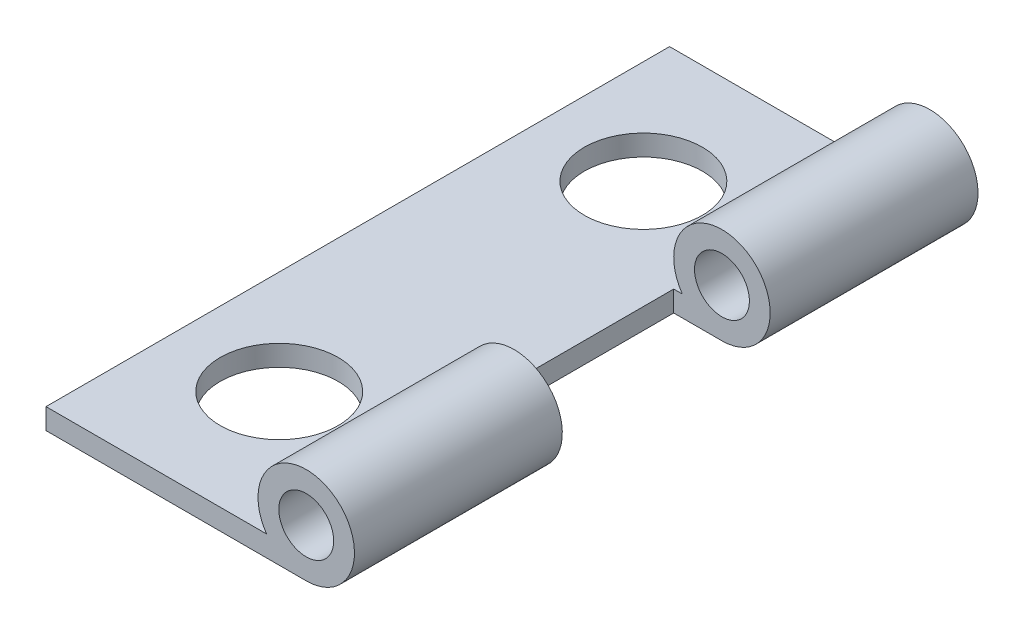
from build123d import *

# Parameters (mm, degrees)
SKETCH1_R               = 0.8382
BOSS_EXTRUDE1_DEPTH     = 19.05
SKETCH7_R               = 1.8034
CUT_EXTRUDE5_DEPTH      = 2.54
SKETCH8_W               = 2.9464
SKETCH8_H               = 6.35
CUT_EXTRUDE6_DEPTH      = 3.3114
CUT_EXTRUDE6_DEPTH_BACK = 1.635


with BuildPart() as part:
    # Sketch1 → Boss-Extrude1 (new body)
    with BuildSketch(Plane.XY):
        with BuildLine():
            Line((-11.0348776, 1.636724806), (-11.0348776, 2.271724806))
            Line((-11.0348776, 2.271724806), (-4.296180386, 2.271724806))
            ThreePointArc((-4.296180386, 2.271724806), (-2.400761669, 4.41475324), (-3.0846776, 1.636724806))
            Line((-3.0846776, 1.636724806), (-11.0348776, 1.636724806))
        make_face()
        with Locations((-3.0846776, 3.109924806)):
            Circle(SKETCH1_R, mode=Mode.SUBTRACT)
    extrude(amount=BOSS_EXTRUDE1_DEPTH)

    # Sketch7 → Cut-Extrude5 (cut)
    with BuildSketch(Plane(origin=(0, 2.271724806, 0), x_dir=(1, 0, 0), z_dir=(0, 1, 0))):
        with Locations((-7.872478375, -3.9624)):
            Circle(SKETCH7_R)
        with Locations((-7.872478375, -15.0876)):
            Circle(SKETCH7_R)
    extrude(amount=-CUT_EXTRUDE5_DEPTH, mode=Mode.SUBTRACT)

    # Sketch8 → Cut-Extrude6 (cut, two sides)
    with BuildSketch(Plane(origin=(0, 2.271724806, 0), x_dir=(1, 0, 0), z_dir=(0, 1, 0))) as cut_extrude6_sk:
        with Locations((-3.0846776, -9.525)):
            Rectangle(SKETCH8_W, SKETCH8_H)
    extrude(amount=CUT_EXTRUDE6_DEPTH, mode=Mode.SUBTRACT)
    extrude(cut_extrude6_sk.sketch, amount=-CUT_EXTRUDE6_DEPTH_BACK, mode=Mode.SUBTRACT)


solid = part.part
